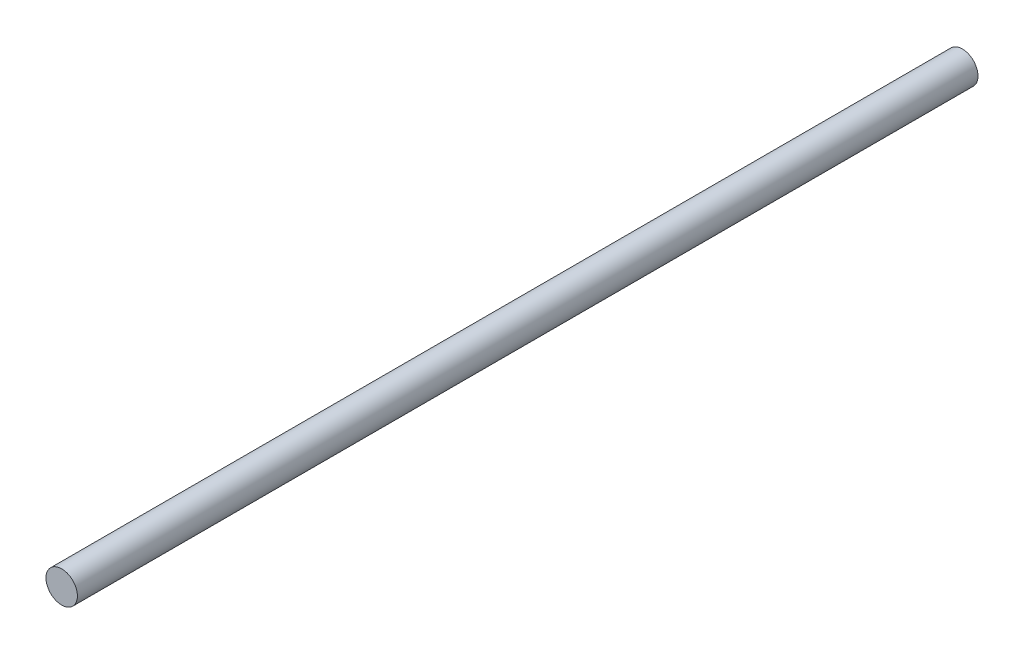
from build123d import *

# Parameters (mm, degrees)
SKETCH_1_R      = 1.5
EXTRUDE_1_DEPTH = 86


with BuildPart() as part:
    # Эскиз1 → Бобышка-Вытянуть1 (new body)
    with BuildSketch(Plane.XY):
        Circle(SKETCH_1_R)
    extrude(amount=EXTRUDE_1_DEPTH)


solid = part.part
